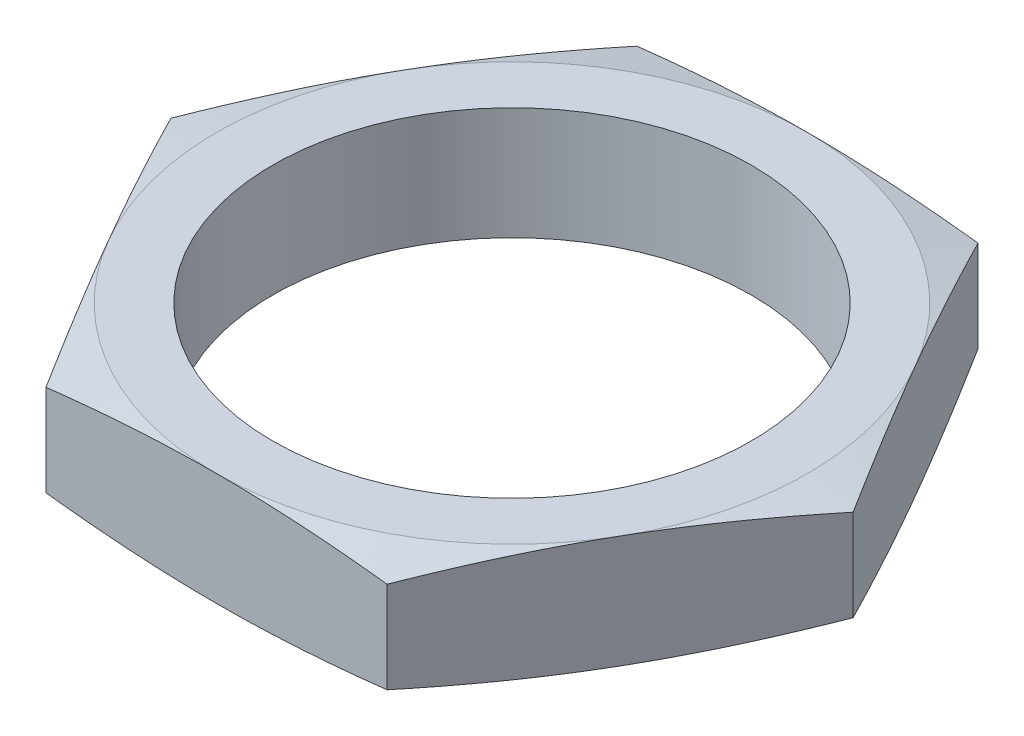
from build123d import *

# Parameters (mm, degrees)
SKETCH_1_R          = 8.5
EXTRUDE_1_DEPTH     = 4
SKETCH_2_OUTSIDE_W  = 76.028
SKETCH_2_OUTSIDE_H  = 72.78
SKETCH_2_OUTSIDE_R  = 10.5
CUT_EXTRUDE_1_DEPTH = 5
CUT_EXTRUDE_1_TAPER = 77
SKETCH_3_OUTSIDE_W  = 76.028
SKETCH_3_OUTSIDE_H  = 72.78
SKETCH_3_OUTSIDE_R  = 10.5
CUT_EXTRUDE_2_DEPTH = 5
CUT_EXTRUDE_2_TAPER = 77


with BuildPart() as part:
    # Эскиз1 → Бобышка-Вытянуть1 (new body)
    with BuildSketch(Plane(origin=(0, 0, 0), x_dir=(1, 0, 0), z_dir=(0, 1, 0))):
        Polygon((12.124355653, 0), (6.062177826, 10.5), (-6.062177826, 10.5), (-12.124355653, 0), (-6.062177826, -10.5), (6.062177826, -10.5), align=None)
        Circle(SKETCH_1_R, mode=Mode.SUBTRACT)
    extrude(amount=EXTRUDE_1_DEPTH)

    # Эскиз2 outside → Вырез-Вытянуть1 (cut, through all)
    with BuildSketch(Plane(origin=(0, 4, 0), x_dir=(1, 0, 0), z_dir=(0, 1, 0))):
        Rectangle(SKETCH_2_OUTSIDE_W, SKETCH_2_OUTSIDE_H)
        Circle(SKETCH_2_OUTSIDE_R, mode=Mode.SUBTRACT)
    extrude(amount=-CUT_EXTRUDE_1_DEPTH, taper=CUT_EXTRUDE_1_TAPER, mode=Mode.SUBTRACT)

    # Эскиз3 outside → Вырез-Вытянуть2 (cut, through all)
    with BuildSketch(Plane.XZ):
        Rectangle(SKETCH_3_OUTSIDE_W, SKETCH_3_OUTSIDE_H)
        Circle(SKETCH_3_OUTSIDE_R, mode=Mode.SUBTRACT)
    extrude(amount=-CUT_EXTRUDE_2_DEPTH, taper=CUT_EXTRUDE_2_TAPER, mode=Mode.SUBTRACT)


solid = part.part
